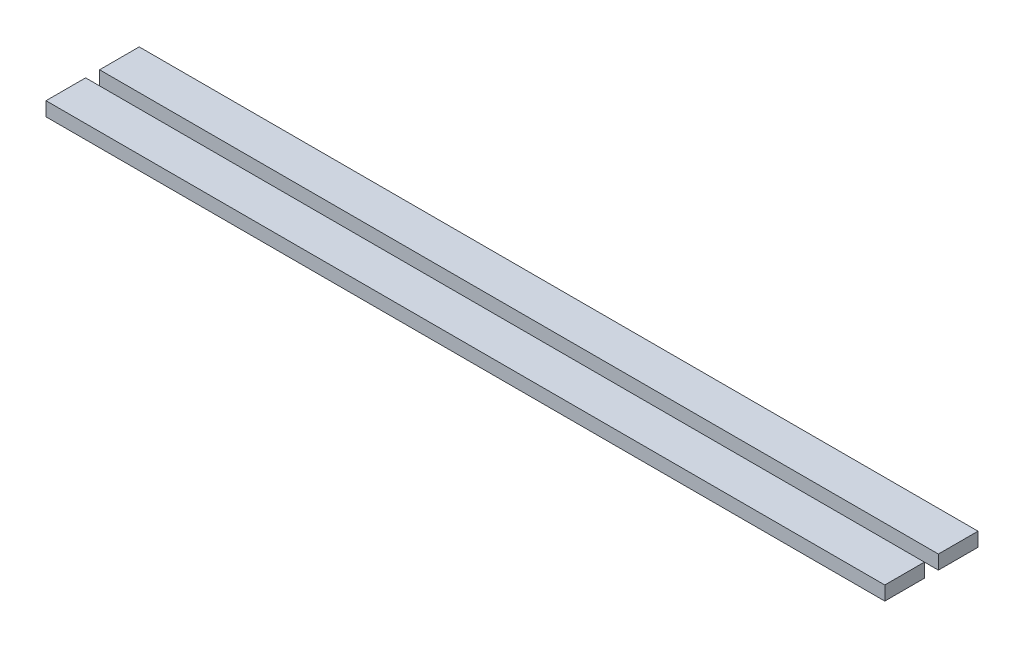
from build123d import *

# Parameters (mm, degrees)
SKETCH1_W               = 180
SKETCH1_H               = 20
BOSS_EXTRUDE1_DEPTH     = 3
CUT_EXTRUDE1_DEPTH      = 10
CUT_EXTRUDE1_DEPTH_BACK = 113.632037148
SKETCH2_W               = 180
SKETCH2_H               = 3


with BuildPart() as part:
    # Sketch1 → Boss-Extrude1 (new body)
    with BuildSketch(Plane(origin=(0, 0, 0), x_dir=(1, 0, 0), z_dir=(0, 1, 0))):
        with Locations((15.283018868, 29.905660377)):
            Rectangle(SKETCH1_W, SKETCH1_H)
    extrude(amount=BOSS_EXTRUDE1_DEPTH)

    # Sketch2 → Cut-Extrude1 (cut, two sides: drawn at the far end of the back side and taken through both)
    with BuildSketch(Plane(origin=(0, 3, 0), x_dir=(1, 0, 0), z_dir=(0, 1, 0)).offset(-CUT_EXTRUDE1_DEPTH_BACK)):
        with Locations((15.283018868, 29.905660377)):
            Rectangle(SKETCH2_W, SKETCH2_H)
    extrude(amount=CUT_EXTRUDE1_DEPTH + CUT_EXTRUDE1_DEPTH_BACK, mode=Mode.SUBTRACT)


with BuildPart() as cut_extrude1_piece_1:
    # of the separate pieces the step leaves, piece 1, a body of its own (cut_extrude1_pieces)
    add(part.part.solids().sort_by_distance((-74.716981132, 0, -19.905660377))[0])


with BuildPart() as cut_extrude1_piece_2:
    # of the separate pieces the step leaves, piece 2, a body of its own (cut_extrude1_pieces)
    add(part.part.solids().sort_by_distance((-74.716981132, 0, -39.905660377))[0])


solid = Compound([cut_extrude1_piece_1.part, cut_extrude1_piece_2.part])
